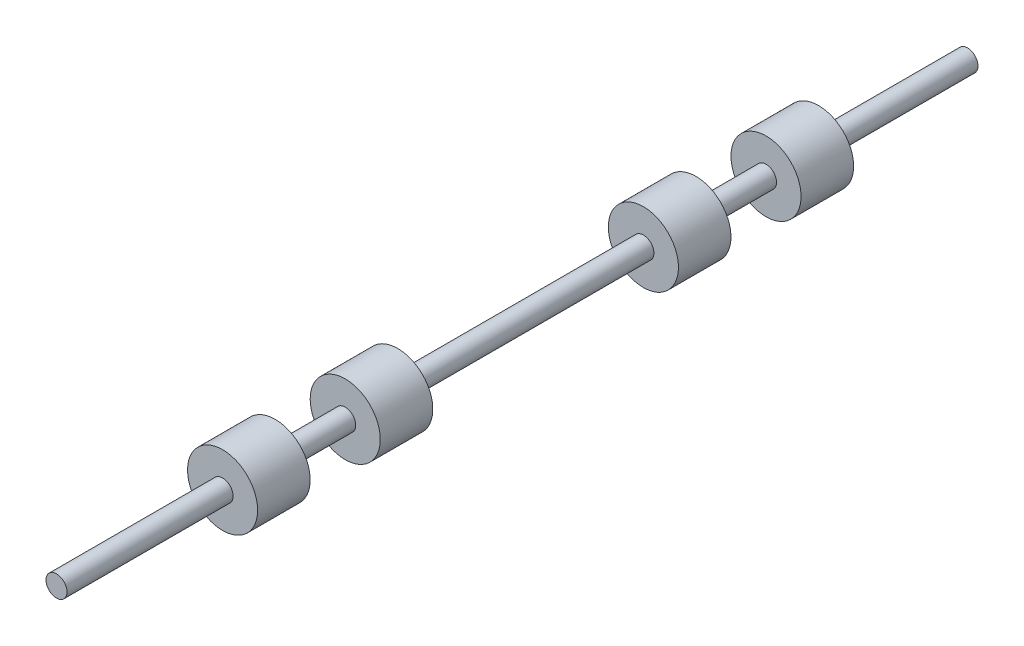
from build123d import *

# Parameters (mm, degrees)
SKETCH1_R           = 0.3
BOSS_EXTRUDE1_DEPTH = 26
SKETCH2_W           = 1
SKETCH2_H           = 1.5


with BuildPart() as part:
    # Sketch1 → Boss-Extrude1 (new body)
    with BuildSketch(Plane.XY):
        Circle(SKETCH1_R)
    extrude(amount=BOSS_EXTRUDE1_DEPTH)

    # Sketch2 → Revolve1 (revolve)
    with BuildSketch(Plane(origin=(0, 0, 0), x_dir=(1, 0, 0), z_dir=(0, 1, 0))):
        with Locations((0.5, -5)):
            Rectangle(SKETCH2_W, SKETCH2_H)
        with Locations((0.5, -8.5)):
            Rectangle(SKETCH2_W, SKETCH2_H)
        with Locations((0.5, -17.01)):
            Rectangle(SKETCH2_W, SKETCH2_H)
        with Locations((0.5, -20.51)):
            Rectangle(SKETCH2_W, SKETCH2_H)
    revolve(axis=Axis((0, 0, 0), (0, 0, 1)))


solid = part.part
